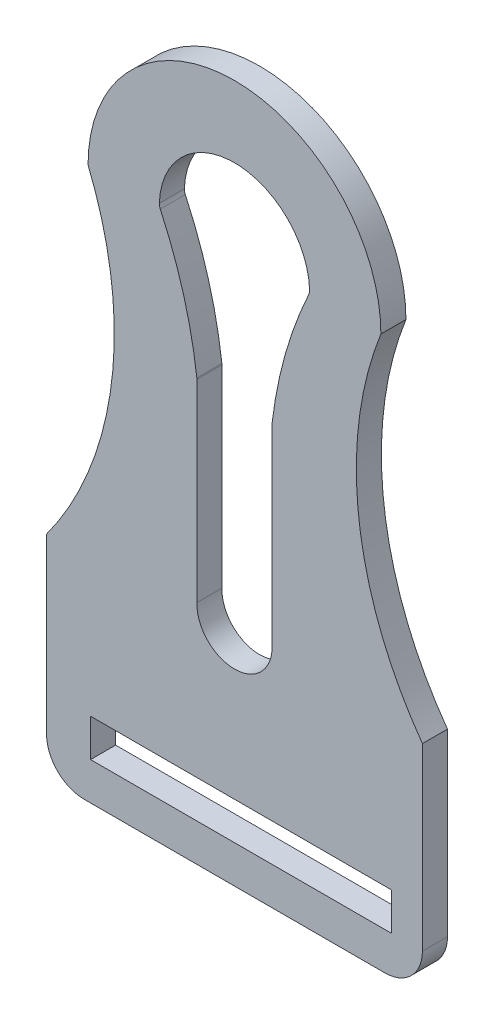
from build123d import *

# Parameters (mm, degrees)
SKETCH1_W      = 76.2
SKETCH1_H      = 9.525
EXTRUDE1_DEPTH = 6.35


with BuildPart() as part:
    # Sketch1 → Extrude1 (new body)
    with BuildSketch(Plane.XY):
        with BuildLine():
            Line((47.625, -59.874659688), (47.625, -105.430018939))
            ThreePointArc((47.625, -105.430018939), (44.835192091, -112.16521103), (38.1, -114.955018939))
            Line((38.1, -114.955018939), (-38.1, -114.955018939))
            ThreePointArc((-38.1, -114.955018939), (-44.835192091, -112.16521103), (-47.625, -105.430018939))
            Line((-47.625, -105.430018939), (-47.625, -61.523712718))
            ThreePointArc((-47.625, -61.523712718), (-31.103765958, -19.76273177), (-37.103282828, 24.744981061))
            ThreePointArc((-37.103282828, 24.744981061), (0, 61.848263889), (37.103282828, 24.744981061))
            ThreePointArc((37.103282828, 24.744981061), (31.556422492, -18.908685267), (47.625, -59.874659688))
        make_face()
        with BuildLine():
            Line((-9.520105929, -57.499718912), (-9.520105929, -8.508405033))
            ThreePointArc((-9.520105929, -8.508405033), (-9.524795338, -8.354131878), (-9.538846249, -8.200428368))
            ThreePointArc((-9.538846249, -8.200428368), (-12.897895618, 8.373789137), (-18.804224779, 24.220024477))
            ThreePointArc((-18.804224779, 24.220024477), (-18.98980734, 24.783579345), (-19.039585391, 25.374812905))
            ThreePointArc((-19.039585391, 25.374812905), (0.000886222, 43.79498104), (19.039643909, 25.373041427))
            ThreePointArc((19.039643909, 25.373041427), (18.990133662, 24.783398196), (18.805538674, 24.221210421))
            ThreePointArc((18.805538674, 24.221210421), (12.876614575, 8.222405207), (9.542532972, -8.510729859))
            ThreePointArc((9.542532972, -8.510729859), (9.529387032, -8.65943529), (9.525, -8.808656182))
            Line((9.525, -8.808656182), (9.525, -57.805018939))
            ThreePointArc((9.525, -57.805018939), (-0.152669626, -67.328795343), (-9.520105929, -57.499718912))
        make_face(mode=Mode.SUBTRACT)
        with Locations((1.633712121, -100.667518939)):
            Rectangle(SKETCH1_W, SKETCH1_H, mode=Mode.SUBTRACT)
    extrude(amount=EXTRUDE1_DEPTH)


solid = part.part
